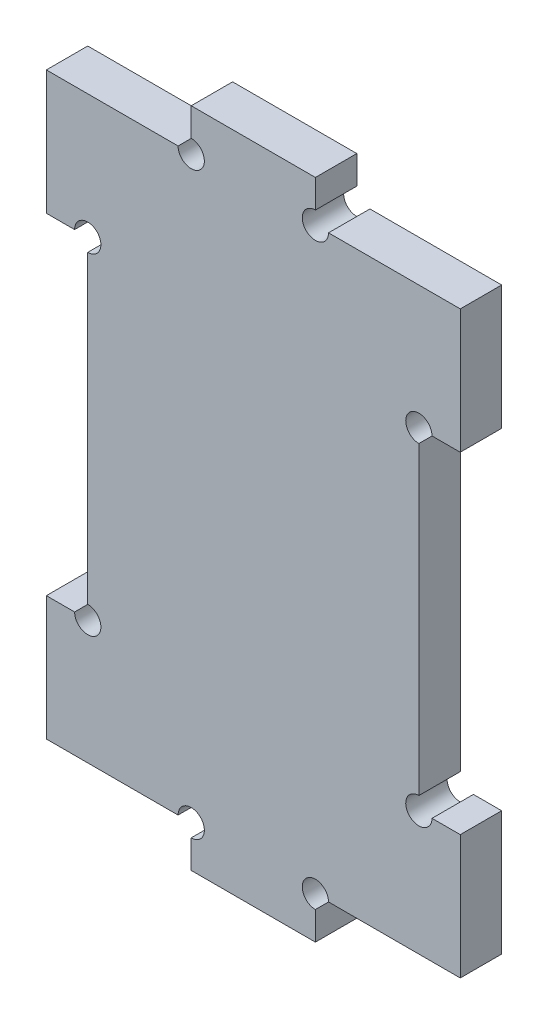
from build123d import *

# Parameters (mm, degrees)
BOSS_EXTRUDE2_DEPTH = 5
SKETCH3_W           = 5
SKETCH3_H           = 40
CUT_EXTRUDE1_DEPTH  = 5
SKETCH4_R           = 1.5875
CUT_EXTRUDE2_DEPTH  = 6


with BuildPart() as part:
    # Sketch2 → Boss-Extrude2 (new body)
    with BuildSketch(Plane.XY):
        Polygon((-7.5, 40), (7.5, 40), (7.5, 35), (25, 35), (25, -35), (7.5, -35), (7.5, -40), (-7.5, -40), (-7.5, -35), (-25, -35), (-25, 35), (-7.5, 35), align=None)
    extrude(amount=BOSS_EXTRUDE2_DEPTH)

    # Sketch3 → Cut-Extrude1 (cut)
    with BuildSketch(Plane.XY.offset(5)):
        with Locations((-22.5, 0)):
            Rectangle(SKETCH3_W, SKETCH3_H)
    cut_extrude1 = extrude(amount=-CUT_EXTRUDE1_DEPTH, mode=Mode.SUBTRACT)

    # Mirror1: Cut-Extrude1 across plane
    add(cut_extrude1.mirror(Plane(origin=(0, 0, 0), x_dir=(0, 0, 1), z_dir=(1, 0, 0))), mode=Mode.SUBTRACT)

    # Sketch4 → Cut-Extrude2 (cut, through all)
    with BuildSketch(Plane.XY.offset(5)):
        with Locations((-7.5, 35)):
            Circle(SKETCH4_R)
        with Locations((7.5, 35)):
            Circle(SKETCH4_R)
        with Locations((20, 20)):
            Circle(SKETCH4_R)
        with Locations((-20, 20)):
            Circle(SKETCH4_R)
        with Locations((-20, -20)):
            Circle(SKETCH4_R)
        with Locations((-7.5, -35)):
            Circle(SKETCH4_R)
        with Locations((7.5, -35)):
            Circle(SKETCH4_R)
        with Locations((20, -20)):
            Circle(SKETCH4_R)
    extrude(amount=-CUT_EXTRUDE2_DEPTH, mode=Mode.SUBTRACT)


solid = part.part
